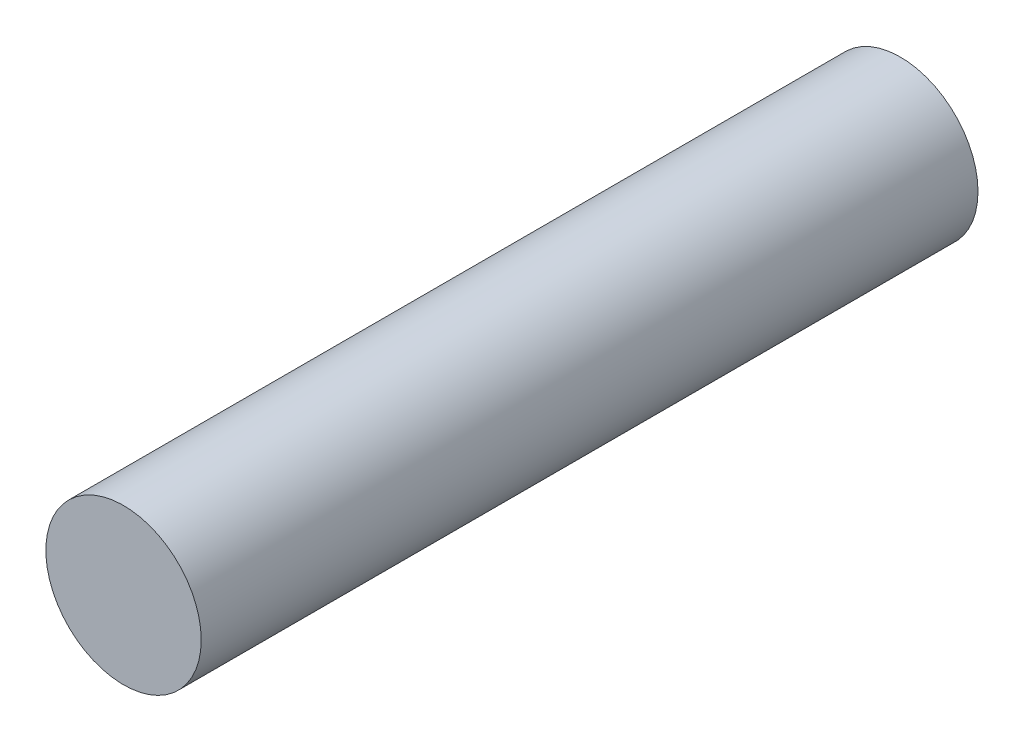
from build123d import *

# Parameters (mm, degrees)
ESQUISSE1_R        = 10
BOSS_EXTRU_1_DEPTH = 100


with BuildPart() as part:
    # Esquisse1 → Boss.-Extru.1 (new body)
    with BuildSketch(Plane.XY):
        Circle(ESQUISSE1_R)
    extrude(amount=BOSS_EXTRU_1_DEPTH)


solid = part.part
